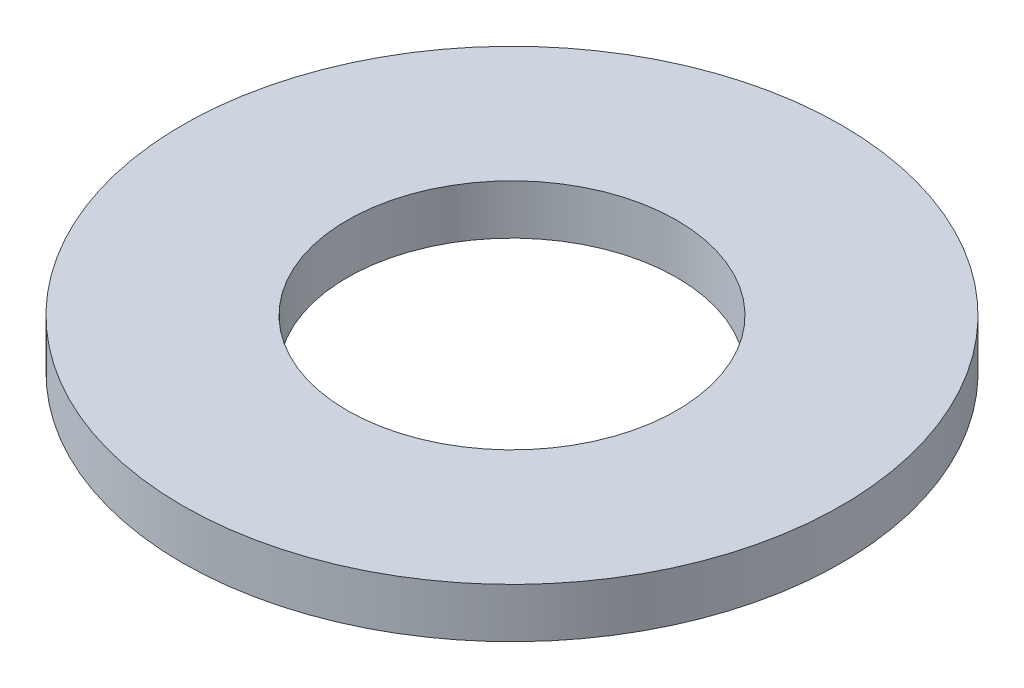
from build123d import *

# Parameters (mm, degrees)
SKETCH1_R           = 13.49375
BOSS_EXTRUDE1_DEPTH = 2.032
SKETCH5_R           = 6.746875
CUT_EXTRUDE1_DEPTH  = 3.032


with BuildPart() as part:
    # Sketch1 → Boss-Extrude1 (new body)
    with BuildSketch(Plane(origin=(0, 0, 0), x_dir=(1, 0, 0), z_dir=(0, 1, 0))):
        Circle(SKETCH1_R)
    extrude(amount=BOSS_EXTRUDE1_DEPTH)

    # Sketch5 → Cut-Extrude1 (cut, through all)
    with BuildSketch(Plane(origin=(0, 2.032, 0), x_dir=(-1, 0, 0), z_dir=(0, 1, 0))):
        Circle(SKETCH5_R)
    extrude(amount=-CUT_EXTRUDE1_DEPTH, mode=Mode.SUBTRACT)


solid = part.part
